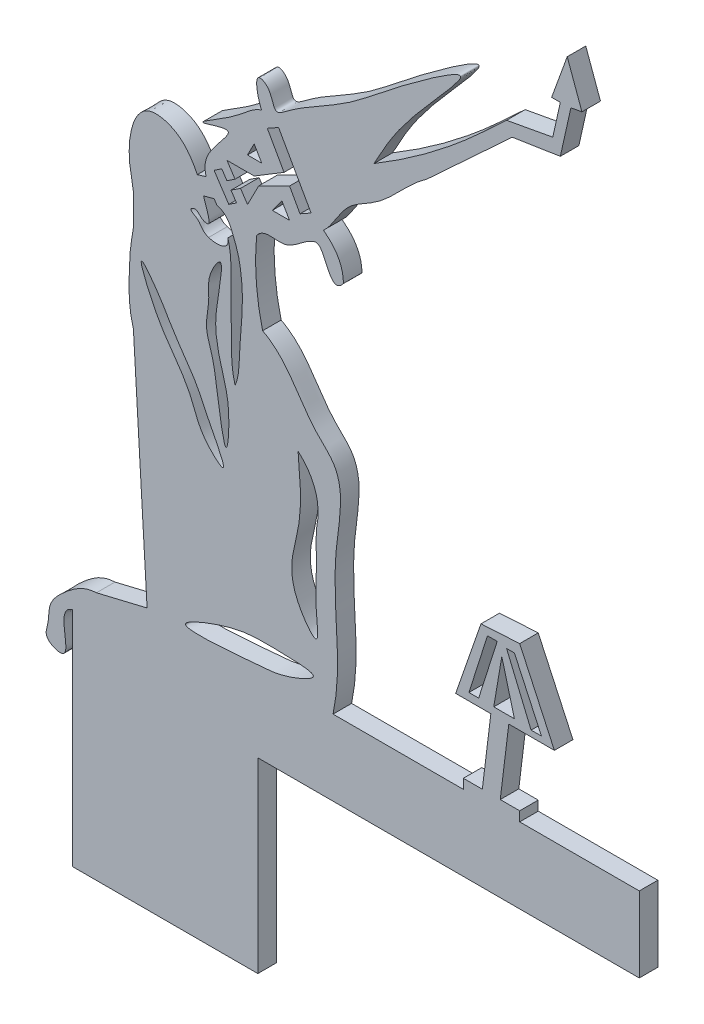
from build123d import *

# Parameters (mm, degrees)
SALIENTE_EXTRUIR1_DEPTH = 2


with BuildPart() as part:
    # Croquis1 → Saliente-Extruir1 (new body)
    with BuildSketch(Plane.XY):
        with BuildLine():
            Line((-94.339141781, 12.979157104), (-95.299941541, 12.689391932))
            add(Edge.make_bspline(
                [(-102.187842914, -5.15552645), (-102.7737715, -3.190955928), (-102.66725925, -0.548098044), (-102.518440834, 2.613300129), (-102.102421774, 4.279208881), (-102.232362672, 5.910333216), (-102.082536436, 7.839411375), (-103.05844999, 11.077562699), (-102.11235717, 16.840241382), (-97.84619581, 15.874960511), (-96.249797019, 14.43060191), (-95.573214267, 13.258339703), (-95.299941541, 12.689391932)],
                knots=[0, 0, 0, 0, 0.120889527, 0.161063046, 0.192252092, 0.224263641, 0.260224044, 0.307556275, 0.4396168, 0.492306237, 0.533661185, 0.571179178, 0.571179178, 0.571179178, 0.571179178], degree=3))
            Line((-102.187842914, -5.15552645), (-100.709586333, -30.475132014))
            Line((-100.709586333, -30.475132014), (-106.172997641, -31.785981011))
            add(Edge.make_bspline(
                [(-108.773405781, -34.660274662), (-110.782968409, -35.187992087), (-107.823428815, -40.445957448), (-111.934723707, -38.789340894), (-111.249598993, -37.092170396), (-111.437008392, -35.173508533), (-109.247579208, -33.045793944), (-107.557034176, -31.839592713), (-106.172997641, -31.785981011)],
                knots=[0, 0, 0, 0, 0.303955806, 0.41643213, 0.488649016, 0.60095305, 0.764815613, 1, 1, 1, 1], degree=3))
            Line((-108.773405781, -34.660274662), (-108.773405781, -43.644089296))
            Line((-108.773405781, -43.644089296), (-108.773405781, -58.644089296))
            Line((-108.773405781, -58.644089296), (-88.773405781, -58.644089296))
            Line((-88.773405781, -58.644089296), (-88.773405781, -43.644089296))
            Line((-88.773405781, -43.644089296), (-88.773405781, -38.493650457))
            Line((-88.773405781, -38.493650457), (-47.646944456, -38.493650457))
            Line((-47.646944456, -38.493650457), (-47.646944456, -34.660274662))
            Line((-47.646944456, -34.660274662), (-47.646944456, -30.362274981))
            Line((-47.646944456, -30.362274981), (-60.539474315, -30.362274981))
            Line((-60.539474315, -30.362274981), (-60.539474315, -29.327254301))
            Line((-60.539474315, -29.327254301), (-62.635775574, -29.327254301))
            Line((-62.635775574, -29.327254301), (-61.71497396, -21.817403633))
            Line((-61.71497396, -21.817403633), (-56.797720926, -21.817403633))
            Line((-56.797720926, -21.817403633), (-58.74084532, -17.609641864))
            Line((-58.74084532, -17.609641864), (-60.539474315, -13.714779371))
            Line((-60.539474315, -13.714779371), (-64.712798795, -13.958434208))
            Line((-64.712798795, -13.958434208), (-65.956836301, -17.541325369))
            Line((-65.956836301, -17.541325369), (-67.441559532, -21.817403633))
            Line((-67.441559532, -21.817403633), (-63.647143325, -21.817403633))
            Line((-63.647143325, -21.817403633), (-64.567944939, -29.327254301))
            Line((-64.567944939, -29.327254301), (-66.613525847, -29.327254301))
            Line((-66.613525847, -29.327254301), (-66.613525847, -30.362274981))
            Line((-66.613525847, -30.362274981), (-80.660994138, -30.362274981))
            add(Edge.make_bspline(
                [(-80.660994138, -30.362274981), (-79.504331408, -24.956317417), (-81.551987005, -17.914664326), (-79.015819464, -7.935775026), (-84.209982636, -3.620853685), (-85.457702277, 0.17894258), (-88.257359935, 1.633976161)],
                knots=[0, 0, 0, 0, 0.447834372, 0.672316628, 0.747681737, 1, 1, 1, 1], degree=3))
            add(Edge.make_bspline(
                [(-88.257359935, 1.633976161), (-89.316503666, 5.890274004), (-88.890752279, 10.228644687)],
                knots=[0, 0, 0, 1, 1, 1], degree=2))
            add(Edge.make_bspline(
                [(-82.79046673, 12.689391895), (-83.806355783, 12.388482808), (-85.58533396, 10.015900883), (-88.070987725, 11.299027902), (-88.890752279, 10.228644687)],
                knots=[0, 0, 0, 0, 0.542449028, 1, 1, 1, 1], degree=3))
            add(Edge.make_bspline(
                [(-79.550809002, 10.393740393), (-81.189084188, 8.298947378), (-81.423496531, 13.485614893), (-82.79046673, 12.689391895)],
                knots=[0, 0, 0, 0, 1, 1, 1, 1], degree=3))
            add(Edge.make_bspline(
                [(-81.695136872, 14.304256192), (-79.543887905, 12.705700613), (-79.550809002, 10.393740393)],
                knots=[0, 0, 0, 1, 1, 1], degree=2))
            add(Edge.make_bspline(
                [(-70.515406479, 24.672982873), (-72.632637263, 23.24536785), (-74.725909905, 20.095230971), (-79.603192458, 17.962622027), (-80.588097056, 15.292580404), (-81.695136872, 14.304256192)],
                knots=[0, 0, 0, 0, 0.497652243, 0.706876576, 1, 1, 1, 1], degree=3))
            Line((-70.515406479, 24.672982873), (-61.342819532, 33.159654723))
            Line((-61.342819532, 33.159654723), (-56.157705262, 33.968041552))
            Line((-56.157705262, 33.968041552), (-55.020652405, 39.071283016))
            Line((-55.020652405, 39.071283016), (-53.828993542, 39.29062685))
            Line((-53.828993542, 39.29062685), (-55.414898244, 43.643429115))
            Line((-55.414898244, 43.643429115), (-57.095001185, 39.010297261))
            Line((-57.095001185, 39.010297261), (-56.157705262, 39.010297261))
            Line((-56.157705262, 39.010297261), (-56.972542319, 35.353202318))
            Line((-56.972542319, 35.353202318), (-57.698624743, 35.219555259))
            Line((-57.698624743, 35.219555259), (-61.952631309, 34.436537452))
            Line((-61.952631309, 34.436537452), (-64.712798795, 31.882771995))
            add(Edge.make_bspline(
                [(-76.251305659, 23.252209753), (-72.097850149, 25.731668914), (-68.251681194, 28.608522995), (-64.712798795, 31.882771995)],
                knots=[0, 0, 0, 0, 1, 1, 1, 1], degree=3))
            add(Edge.make_bspline(
                [(-88.350203409, 22.200174443), (-88.518321358, 22.404826243), (-89.015908563, 23.997718387), (-88.803999262, 25.360452923), (-87.170502631, 24.558880778), (-87.157249524, 22.281075667), (-84.731872643, 24.16359178), (-82.618662001, 25.404111128), (-78.565642649, 27.696292878), (-74.724628423, 31.011473293), (-63.588084898, 39.148234646), (-72.579892278, 29.377701765), (-74.535205064, 26.473779542), (-76.251305659, 23.252209753)],
                knots=[0.009544442, 0.009544442, 0.009544442, 0.009544442, 0.045606886, 0.065001926, 0.086832548, 0.132571738, 0.158800342, 0.242149552, 0.321857051, 0.444076865, 0.653290475, 0.787620555, 1, 1, 1, 1], degree=3))
            add(Edge.make_bspline(
                [(-94.339141781, 12.979157104), (-94.528018072, 13.605430765), (-94.545906773, 15.619660344), (-90.004535454, 19.501302705), (-96.777448971, 16.954133487), (-90.903699691, 20.107305194), (-89.658345358, 21.643227958), (-88.547869509, 22.129073009), (-88.350203409, 22.200174443)],
                knots=[0.128356065, 0.128356065, 0.128356065, 0.128356065, 0.23582505, 0.449269477, 0.587283636, 0.797010564, 0.963366152, 0.995107075, 0.995107075, 0.995107075, 0.995107075], degree=3))
        make_face()
        with BuildLine():
            add(Edge.make_bspline(
                [(-96.530168095, -29.821985942), (-96.261292193, -29.396472435), (-90.956908889, -27.284260623), (-88.204093775, -27.352681396), (-81.080112313, -27.536937926), (-86.086826499, -29.655177864), (-89.452443586, -29.823969758), (-97.012810947, -30.585799475), (-96.530168095, -29.821985942)],
                knots=[0, 0, 0, 0, 0.152659709, 0.388236534, 0.500805619, 0.614313418, 0.725969799, 1, 1, 1, 1], degree=3))
        make_face(mode=Mode.SUBTRACT)
        with BuildLine():
            add(Edge.make_bspline(
                [(-84.431899237, -7.709756825), (-84.216427291, -10.114451371), (-83.782704801, -14.954849973), (-86.233514752, -19.849532521), (-81.966249888, -25.58354214), (-82.675347392, -20.686147862), (-82.329414913, -17.914974578), (-82.545287605, -15.163883111), (-82.44834955, -13.958434208)],
                knots=[0, 0, 0, 0, 0.223815698, 0.45051759, 0.55019019, 0.627147437, 0.763698267, 0.878113222, 0.878113222, 0.878113222, 0.878113222], degree=3))
            add(Edge.make_bspline(
                [(-82.44834955, -13.958434208), (-81.661761848, -10.151014898), (-84.431899237, -7.709756825)],
                knots=[0, 0, 0, 1, 1, 1], degree=2))
        make_face(mode=Mode.SUBTRACT)
        Polygon((-66.011653525, -21.020274922), (-65.012160846, -17.869331899), (-64.012668166, -14.718388876), (-62.963564469, -14.718388876), (-64.962549827, -21.020274922), align=None, mode=Mode.SUBTRACT)
        Polygon((-63.335469713, -21.020274922), (-62.469598276, -15.890132042), (-61.105603615, -21.020274922), align=None, mode=Mode.SUBTRACT)
        Polygon((-61.105603615, -14.877949199), (-59.648715981, -18.028892222), (-58.191828346, -21.179835245), (-59.309904903, -21.179835245), (-61.952631309, -14.877949199), align=None, mode=Mode.SUBTRACT)
        with BuildLine():
            add(Edge.make_bspline(
                [(-92.579972036, -13.299498164), (-92.864626221, -13.279767093), (-95.127935696, -11.255449199), (-95.659009971, -8.717503822), (-97.673010938, -5.487375026), (-99.577602152, -3.209350075), (-102.425375812, 3.510337532), (-99.104688494, -0.961447818), (-97.77275536, -3.550934742), (-95.383025533, -6.61815073), (-94.255217835, -9.436019007), (-92.08849217, -13.33356555), (-92.579972036, -13.299498164)],
                knots=[0, 0, 0, 0, 0.06596978, 0.173694359, 0.257423461, 0.368748445, 0.501493128, 0.588429416, 0.673259366, 0.798127408, 0.886097516, 1, 1, 1, 1], degree=3))
        make_face(mode=Mode.SUBTRACT)
        with BuildLine():
            add(Edge.make_bspline(
                [(-92.170187868, -11.215804236), (-91.923609531, -11.069868001), (-91.71138489, -7.103879626), (-92.621395089, -4.445200713), (-93.328699188, -1.506418281), (-93.391291011, 1.215910682), (-92.073391495, 7.41187784), (-94.316819812, 3.732406296), (-93.864370244, 1.571857584), (-94.598418896, -0.905567036), (-93.584566333, -3.525966428), (-93.171163083, -6.408455973), (-92.46251939, -11.38881928), (-92.170187868, -11.215804236)],
                knots=[0, 0, 0, 0, 0.125787463, 0.198193279, 0.28004505, 0.36687175, 0.494897358, 0.553279478, 0.621104426, 0.69794673, 0.764945353, 0.85087238, 1, 1, 1, 1], degree=3))
        make_face(mode=Mode.SUBTRACT)
        with BuildLine():
            add(Edge.make_bspline(
                [(-94.065595912, 7.455255739), (-94.87166849, 7.677859944), (-94.766247113, 8.459801621), (-96.291548757, 9.069538922), (-95.306830927, 9.541001748), (-95.005404723, 8.786225144), (-93.928961814, 8.508522846), (-94.164909936, 9.852080841), (-94.418324544, 10.294911695), (-94.625024374, 11.045887443)],
                knots=[0, 0, 0, 0, 0.2563358, 0.360203599, 0.430018497, 0.554190489, 0.661729466, 0.733846926, 1, 1, 1, 1], degree=3))
            Line((-94.625024374, 11.045887443), (-93.489309799, 11.348698123))
            Line((-93.489309799, 11.348698123), (-93.178333131, 10.890169112))
            add(Edge.make_bspline(
                [(-93.178333131, 10.890169112), (-92.122933783, 10.655486236), (-91.49824843, 9.184749596), (-90.790677742, 7.259888778), (-90.543997329, 5.600691804), (-90.404321322, 3.937350992), (-90.474814911, 1.506403706), (-90.804435807, -1.457899768), (-90.767895607, -3.909041627), (-91.225991597, -4.938116654)],
                knots=[0, 0, 0, 0, 0.167695191, 0.2693692, 0.369432746, 0.465333689, 0.567825532, 0.80308404, 1, 1, 1, 1], degree=3))
            add(Edge.make_bspline(
                [(-91.225991597, -4.938116654), (-91.647483727, -3.519126906), (-91.606036905, -1.418152691), (-91.642820275, 1.338522456), (-91.673235903, 4.359856026), (-91.546240157, 6.746235878), (-91.999129975, 8.440791039)],
                knots=[0, 0, 0, 0, 0.324988069, 0.467575943, 0.616210513, 1, 1, 1, 1], degree=3))
            add(Edge.make_bspline(
                [(-94.065595912, 7.455255739), (-93.595881869, 7.235194666), (-92.065387861, 7.201799229), (-91.949117395, 8.109229879), (-91.999129975, 8.440791039)],
                knots=[0, 0, 0, 0, 0.358045826, 0.527791416, 0.527791416, 0.527791416, 0.527791416], degree=3))
        make_face(mode=Mode.SUBTRACT)
        Polygon((-89.885067116, 17.233133546), (-89.16720229, 18.633332065), (-88.350203409, 17.233133546), align=None, mode=Mode.SUBTRACT)
        Polygon((-89.16720229, 15.628513009), (-85.94430571, 17.57891439), (-87.751071667, 20.791860941), (-86.53464687, 21.47590435), (-83.028094772, 15.240251952), (-84.226468039, 14.566359627), (-85.354143188, 16.603713699), (-88.664304008, 14.9663846), (-89.885067116, 12.610486329), (-90.63625411, 13.741782001), (-91.665648763, 13.058257884), (-91.07100286, 12.162714773), (-91.903133261, 11.610175282), (-93.489309799, 13.998974166), (-92.657179397, 14.551513657), (-92.105305929, 13.720386293), (-91.225991597, 14.304256192), (-92.105305929, 15.628513009), align=None, mode=Mode.SUBTRACT)
        Polygon((-87.210132239, 13.397214484), (-86.17077746, 14.796788123), (-85.354143188, 13.397214484), align=None, mode=Mode.SUBTRACT)
    extrude(amount=SALIENTE_EXTRUIR1_DEPTH)


solid = part.part
